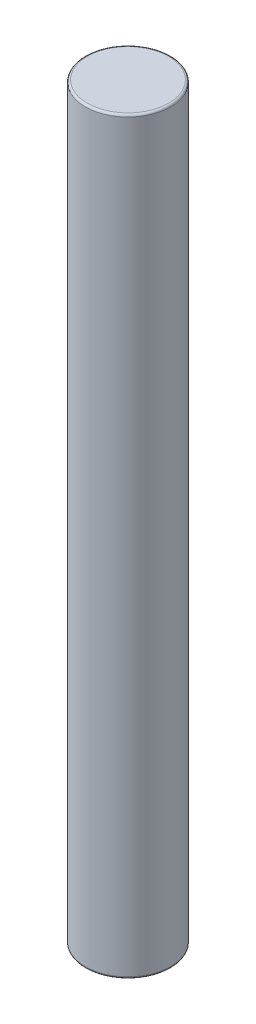
from build123d import *

# Parameters (mm, degrees)
SKETCH1_R           = 4
BOSS_EXTRUDE1_DEPTH = 70
FILLET1_R           = 0.2


with BuildPart() as part:
    # Sketch1 → Boss-Extrude1 (new body)
    with BuildSketch(Plane(origin=(0, 0, 0), x_dir=(1, 0, 0), z_dir=(0, 1, 0))):
        Circle(SKETCH1_R)
    extrude(amount=BOSS_EXTRUDE1_DEPTH)

    # Fillet1
    fillet1_edges = [part.edges().sort_by_distance(p)[0] for p in [
        (-4, 0, 0),
        (-4, 70, 0),
    ]]
    fillet(fillet1_edges, radius=FILLET1_R)


solid = part.part
